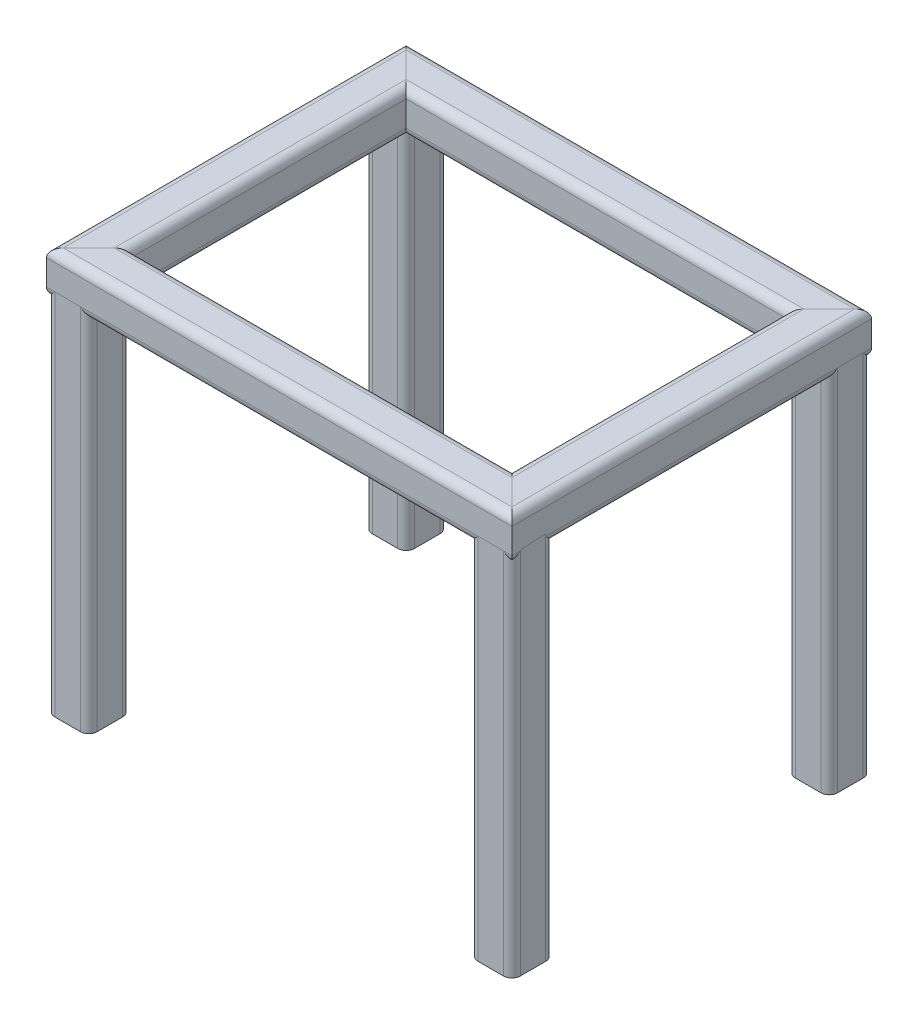
from build123d import *

# Parameters (mm, degrees)
STRUCTURAL_MEMBER1_DEPTH      = 215.142135624
STRUCTURAL_MEMBER1_DEPTH_BACK = 15.142135624
STRUCTURAL_MEMBER1_2_DEPTH    = 180.284271247
STRUCTURAL_MEMBER1_3_DEPTH    = 230.284271247
STRUCTURAL_MEMBER1_4_DEPTH    = 180.284271247
STRUCTURAL_MEMBER2_DEPTH      = 180
STRUCTURAL_MEMBER2_2_DEPTH    = 180
STRUCTURAL_MEMBER2_3_DEPTH    = 180
STRUCTURAL_MEMBER2_4_DEPTH    = 180


with BuildPart() as part:
    # Sketch1 → Structural Member1 (new body, two sides)
    with BuildSketch(Plane(origin=(-100, 0, 75), x_dir=(0, 0, -1), z_dir=(1, 0, 0))) as structural_member1_sk:
        with BuildLine():
            Line((-6, -10), (6, -10))
            ThreePointArc((6, -10), (8.828427125, -8.828427125), (10, -6))
            Line((10, -6), (10, 6))
            ThreePointArc((10, 6), (8.828427125, 8.828427125), (6, 10))
            Line((6, 10), (-6, 10))
            ThreePointArc((-6, 10), (-8.828427125, 8.828427125), (-10, 6))
            Line((-10, 6), (-10, -6))
            ThreePointArc((-10, -6), (-8.828427125, -8.828427125), (-6, -10))
        make_face()
        with BuildLine():
            Line((-6, -8), (6, -8))
            ThreePointArc((6, -8), (7.414213562, -7.414213562), (8, -6))
            Line((8, -6), (8, 6))
            ThreePointArc((8, 6), (7.414213562, 7.414213562), (6, 8))
            Line((6, 8), (-6, 8))
            ThreePointArc((-6, 8), (-7.414213562, 7.414213562), (-8, 6))
            Line((-8, 6), (-8, -6))
            ThreePointArc((-8, -6), (-7.414213562, -7.414213562), (-6, -8))
        make_face(mode=Mode.SUBTRACT)
    extrude(amount=STRUCTURAL_MEMBER1_DEPTH)
    extrude(structural_member1_sk.sketch, amount=-STRUCTURAL_MEMBER1_DEPTH_BACK)

    # Structural Member1 mitre 1
    split(bisect_by=Plane(origin=(-100, 0, 75), x_dir=(0, 1, 0), z_dir=(0.707106781, 0, 0.707106781)), keep=Keep.TOP)

    # Structural Member1 mitre 2
    split(bisect_by=Plane(origin=(100, 0, 75), x_dir=(0, -1, 0), z_dir=(-0.707106781, 0, 0.707106781)), keep=Keep.TOP)


with BuildPart() as body_2:
    # Sketch1 on segment 2 (carried to segment 2) → Structural Member1 2 (new body)
    with BuildSketch(Plane(origin=(100, 0, 90.142135624), x_dir=(-1, 0, 0), z_dir=(0, 0, -1))):
        with BuildLine():
            Line((-6, -10), (6, -10))
            ThreePointArc((6, -10), (8.828427125, -8.828427125), (10, -6))
            Line((10, -6), (10, 6))
            ThreePointArc((10, 6), (8.828427125, 8.828427125), (6, 10))
            Line((6, 10), (-6, 10))
            ThreePointArc((-6, 10), (-8.828427125, 8.828427125), (-10, 6))
            Line((-10, 6), (-10, -6))
            ThreePointArc((-10, -6), (-8.828427125, -8.828427125), (-6, -10))
        make_face()
        with BuildLine():
            Line((-6, -8), (6, -8))
            ThreePointArc((6, -8), (7.414213562, -7.414213562), (8, -6))
            Line((8, -6), (8, 6))
            ThreePointArc((8, 6), (7.414213562, 7.414213562), (6, 8))
            Line((6, 8), (-6, 8))
            ThreePointArc((-6, 8), (-7.414213562, 7.414213562), (-8, 6))
            Line((-8, 6), (-8, -6))
            ThreePointArc((-8, -6), (-7.414213562, -7.414213562), (-6, -8))
        make_face(mode=Mode.SUBTRACT)
    extrude(amount=STRUCTURAL_MEMBER1_2_DEPTH)

    # Structural Member1 2 mitre 1
    split(bisect_by=Plane(origin=(100, 0, 75), x_dir=(0, 1, 0), z_dir=(0.707106781, 0, -0.707106781)), keep=Keep.TOP)

    # Structural Member1 2 mitre 2
    split(bisect_by=Plane(origin=(100, 0, -75), x_dir=(0, 1, 0), z_dir=(0.707106781, 0, 0.707106781)), keep=Keep.TOP)


with BuildPart() as body_3:
    # Sketch1 on segment 3 (carried to segment 3) → Structural Member1 3 (new body)
    with BuildSketch(Plane(origin=(-115.142135624, 0, -75), x_dir=(0, 0, -1), z_dir=(1, 0, 0))):
        with BuildLine():
            Line((-6, -10), (6, -10))
            ThreePointArc((6, -10), (8.828427125, -8.828427125), (10, -6))
            Line((10, -6), (10, 6))
            ThreePointArc((10, 6), (8.828427125, 8.828427125), (6, 10))
            Line((6, 10), (-6, 10))
            ThreePointArc((-6, 10), (-8.828427125, 8.828427125), (-10, 6))
            Line((-10, 6), (-10, -6))
            ThreePointArc((-10, -6), (-8.828427125, -8.828427125), (-6, -10))
        make_face()
        with BuildLine():
            Line((-6, -8), (6, -8))
            ThreePointArc((6, -8), (7.414213562, -7.414213562), (8, -6))
            Line((8, -6), (8, 6))
            ThreePointArc((8, 6), (7.414213562, 7.414213562), (6, 8))
            Line((6, 8), (-6, 8))
            ThreePointArc((-6, 8), (-7.414213562, 7.414213562), (-8, 6))
            Line((-8, 6), (-8, -6))
            ThreePointArc((-8, -6), (-7.414213562, -7.414213562), (-6, -8))
        make_face(mode=Mode.SUBTRACT)
    extrude(amount=STRUCTURAL_MEMBER1_3_DEPTH)

    # Structural Member1 3 mitre 1
    split(bisect_by=Plane(origin=(-100, 0, -75), x_dir=(0, 1, 0), z_dir=(0.707106781, 0, -0.707106781)), keep=Keep.TOP)

    # Structural Member1 3 mitre 2
    split(bisect_by=Plane(origin=(100, 0, -75), x_dir=(0, -1, 0), z_dir=(-0.707106781, 0, -0.707106781)), keep=Keep.TOP)


with BuildPart() as body_4:
    # Sketch1 on segment 4 (carried to segment 4) → Structural Member1 4 (new body)
    with BuildSketch(Plane(origin=(-100, 0, 90.142135624), x_dir=(-1, 0, 0), z_dir=(0, 0, -1))):
        with BuildLine():
            Line((-6, -10), (6, -10))
            ThreePointArc((6, -10), (8.828427125, -8.828427125), (10, -6))
            Line((10, -6), (10, 6))
            ThreePointArc((10, 6), (8.828427125, 8.828427125), (6, 10))
            Line((6, 10), (-6, 10))
            ThreePointArc((-6, 10), (-8.828427125, 8.828427125), (-10, 6))
            Line((-10, 6), (-10, -6))
            ThreePointArc((-10, -6), (-8.828427125, -8.828427125), (-6, -10))
        make_face()
        with BuildLine():
            Line((-6, -8), (6, -8))
            ThreePointArc((6, -8), (7.414213562, -7.414213562), (8, -6))
            Line((8, -6), (8, 6))
            ThreePointArc((8, 6), (7.414213562, 7.414213562), (6, 8))
            Line((6, 8), (-6, 8))
            ThreePointArc((-6, 8), (-7.414213562, 7.414213562), (-8, 6))
            Line((-8, 6), (-8, -6))
            ThreePointArc((-8, -6), (-7.414213562, -7.414213562), (-6, -8))
        make_face(mode=Mode.SUBTRACT)
    extrude(amount=STRUCTURAL_MEMBER1_4_DEPTH)

    # Structural Member1 4 mitre 1
    split(bisect_by=Plane(origin=(-100, 0, 75), x_dir=(0, -1, 0), z_dir=(-0.707106781, 0, -0.707106781)), keep=Keep.TOP)

    # Structural Member1 4 mitre 2
    split(bisect_by=Plane(origin=(-100, 0, -75), x_dir=(0, -1, 0), z_dir=(-0.707106781, 0, 0.707106781)), keep=Keep.TOP)


with BuildPart() as body_5:
    # Sketch17 → Structural Member2 (new body)
    with BuildSketch(Plane(origin=(-100, 0, 75), x_dir=(1, 0, 0), z_dir=(0, -1, 0))):
        with BuildLine():
            Line((-6, -10), (6, -10))
            ThreePointArc((6, -10), (8.828427125, -8.828427125), (10, -6))
            Line((10, -6), (10, 6))
            ThreePointArc((10, 6), (8.828427125, 8.828427125), (6, 10))
            Line((6, 10), (-6, 10))
            ThreePointArc((-6, 10), (-8.828427125, 8.828427125), (-10, 6))
            Line((-10, 6), (-10, -6))
            ThreePointArc((-10, -6), (-8.828427125, -8.828427125), (-6, -10))
        make_face()
        with BuildLine():
            Line((-6, -8), (6, -8))
            ThreePointArc((6, -8), (7.414213562, -7.414213562), (8, -6))
            Line((8, -6), (8, 6))
            ThreePointArc((8, 6), (7.414213562, 7.414213562), (6, 8))
            Line((6, 8), (-6, 8))
            ThreePointArc((-6, 8), (-7.414213562, 7.414213562), (-8, 6))
            Line((-8, 6), (-8, -6))
            ThreePointArc((-8, -6), (-7.414213562, -7.414213562), (-6, -8))
        make_face(mode=Mode.SUBTRACT)
    extrude(amount=STRUCTURAL_MEMBER2_DEPTH)


with BuildPart() as body_6:
    # Sketch17 on segment 2 (carried to segment 2) → Structural Member2 2 (new body)
    with BuildSketch(Plane(origin=(100, 0, 75), x_dir=(1, 0, 0), z_dir=(0, -1, 0))):
        with BuildLine():
            Line((-6, -10), (6, -10))
            ThreePointArc((6, -10), (8.828427125, -8.828427125), (10, -6))
            Line((10, -6), (10, 6))
            ThreePointArc((10, 6), (8.828427125, 8.828427125), (6, 10))
            Line((6, 10), (-6, 10))
            ThreePointArc((-6, 10), (-8.828427125, 8.828427125), (-10, 6))
            Line((-10, 6), (-10, -6))
            ThreePointArc((-10, -6), (-8.828427125, -8.828427125), (-6, -10))
        make_face()
        with BuildLine():
            Line((-6, -8), (6, -8))
            ThreePointArc((6, -8), (7.414213562, -7.414213562), (8, -6))
            Line((8, -6), (8, 6))
            ThreePointArc((8, 6), (7.414213562, 7.414213562), (6, 8))
            Line((6, 8), (-6, 8))
            ThreePointArc((-6, 8), (-7.414213562, 7.414213562), (-8, 6))
            Line((-8, 6), (-8, -6))
            ThreePointArc((-8, -6), (-7.414213562, -7.414213562), (-6, -8))
        make_face(mode=Mode.SUBTRACT)
    extrude(amount=STRUCTURAL_MEMBER2_2_DEPTH)


with BuildPart() as body_7:
    # Sketch17 on segment 3 (carried to segment 3) → Structural Member2 3 (new body)
    with BuildSketch(Plane(origin=(-100, 0, -75), x_dir=(1, 0, 0), z_dir=(0, -1, 0))):
        with BuildLine():
            Line((-6, -10), (6, -10))
            ThreePointArc((6, -10), (8.828427125, -8.828427125), (10, -6))
            Line((10, -6), (10, 6))
            ThreePointArc((10, 6), (8.828427125, 8.828427125), (6, 10))
            Line((6, 10), (-6, 10))
            ThreePointArc((-6, 10), (-8.828427125, 8.828427125), (-10, 6))
            Line((-10, 6), (-10, -6))
            ThreePointArc((-10, -6), (-8.828427125, -8.828427125), (-6, -10))
        make_face()
        with BuildLine():
            Line((-6, -8), (6, -8))
            ThreePointArc((6, -8), (7.414213562, -7.414213562), (8, -6))
            Line((8, -6), (8, 6))
            ThreePointArc((8, 6), (7.414213562, 7.414213562), (6, 8))
            Line((6, 8), (-6, 8))
            ThreePointArc((-6, 8), (-7.414213562, 7.414213562), (-8, 6))
            Line((-8, 6), (-8, -6))
            ThreePointArc((-8, -6), (-7.414213562, -7.414213562), (-6, -8))
        make_face(mode=Mode.SUBTRACT)
    extrude(amount=STRUCTURAL_MEMBER2_3_DEPTH)


with BuildPart() as body_8:
    # Sketch17 on segment 4 (carried to segment 4) → Structural Member2 4 (new body)
    with BuildSketch(Plane(origin=(100, 0, -75), x_dir=(1, 0, 0), z_dir=(0, -1, 0))):
        with BuildLine():
            Line((-6, -10), (6, -10))
            ThreePointArc((6, -10), (8.828427125, -8.828427125), (10, -6))
            Line((10, -6), (10, 6))
            ThreePointArc((10, 6), (8.828427125, 8.828427125), (6, 10))
            Line((6, 10), (-6, 10))
            ThreePointArc((-6, 10), (-8.828427125, 8.828427125), (-10, 6))
            Line((-10, 6), (-10, -6))
            ThreePointArc((-10, -6), (-8.828427125, -8.828427125), (-6, -10))
        make_face()
        with BuildLine():
            Line((-6, -8), (6, -8))
            ThreePointArc((6, -8), (7.414213562, -7.414213562), (8, -6))
            Line((8, -6), (8, 6))
            ThreePointArc((8, 6), (7.414213562, 7.414213562), (6, 8))
            Line((6, 8), (-6, 8))
            ThreePointArc((-6, 8), (-7.414213562, 7.414213562), (-8, 6))
            Line((-8, 6), (-8, -6))
            ThreePointArc((-8, -6), (-7.414213562, -7.414213562), (-6, -8))
        make_face(mode=Mode.SUBTRACT)
    extrude(amount=STRUCTURAL_MEMBER2_4_DEPTH)


solid = Compound([part.part, body_2.part, body_3.part, body_4.part, body_5.part, body_6.part, body_7.part, body_8.part])
